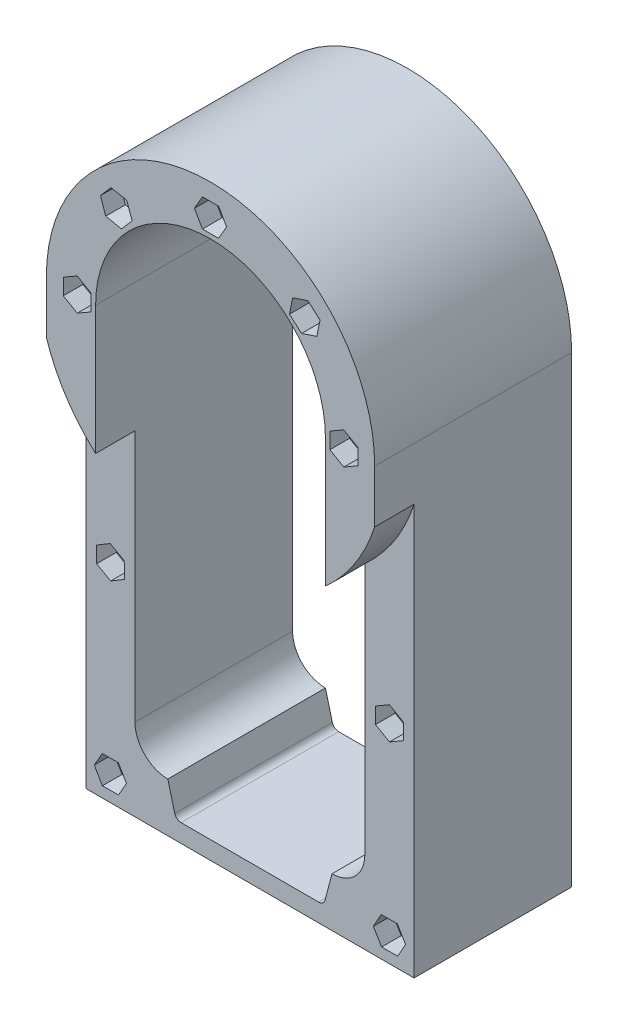
from build123d import *

# Parameters (mm, degrees)
SALIENTE_EXTRUIR1_DEPTH = 60
CROQUIS2_R              = 3
CORTAR_EXTRUIR1_DEPTH   = 60
CORTAR_EXTRUIR2_DEPTH   = 6
CORTAR_EXTRUIR3_DEPTH   = 12
CROQUIS5_R              = 3
CORTAR_EXTRUIR4_DEPTH   = 48
CORTAR_EXTRUIR5_DEPTH   = 6
CORTAR_EXTRUIR6_DEPTH   = 6
CORTAR_EXTRUIR7_DEPTH   = 48


with BuildPart() as part:
    # Croquis1 → Saliente-Extruir1 (new body)
    with BuildSketch(Plane.XY):
        with BuildLine():
            Line((-50, 0), (-50, -141))
            Line((-50, -141), (50, -141))
            Line((50, -141), (50, 0))
            ThreePointArc((50, 0), (0, 50), (-50, 0))
        make_face()
        with BuildLine():
            Line((-35, 0), (-35, -116))
            ThreePointArc((-35, -116), (-32.071067812, -123.071067812), (-25, -126))
            Line((-25, -126), (25, -126))
            ThreePointArc((25, -126), (32.071067812, -123.071067812), (35, -116))
            Line((35, -116), (35, 0))
            ThreePointArc((35, 0), (0, 35), (-35, 0))
        make_face(mode=Mode.SUBTRACT)
    extrude(amount=SALIENTE_EXTRUIR1_DEPTH)

    # Croquis2 → Cortar-Extruir1 (cut)
    with BuildSketch(Plane.XY.offset(60)):
        with Locations((0, 40.605)):
            Circle(CROQUIS2_R)
        with Locations((28.71207085, 28.71207085)):
            Circle(CROQUIS2_R)
        with Locations((40.605, 0)):
            Circle(CROQUIS2_R)
        with Locations((-40.605, 0)):
            Circle(CROQUIS2_R)
        with Locations((-28.71207085, 28.71207085)):
            Circle(CROQUIS2_R)
    extrude(amount=-CORTAR_EXTRUIR1_DEPTH, mode=Mode.SUBTRACT)

    # Croquis3 → Cortar-Extruir2 (cut)
    with BuildSketch(Plane.XY.offset(60)):
        Polygon((4.907477288, 40.605), (2.453738644, 44.855), (-2.453738644, 44.855), (-4.907477288, 40.605), (-2.453738644, 36.355), (2.453738644, 36.355), align=None)
        Polygon((33.365133185, 30.271668311), (29.687950997, 33.521539768), (25.034888662, 31.961942307), (24.059008515, 27.152473389), (27.736190704, 23.902601932), (32.389253039, 25.462199393), align=None)
        Polygon((40.605, -4.907477288), (44.855, -2.453738644), (44.855, 2.453738644), (40.605, 4.907477288), (36.355, 2.453738644), (36.355, -2.453738644), align=None)
        Polygon((-33.528922476, 29.650832668), (-31.933488245, 25.009935885), (-27.11663662, 24.071174067), (-23.895219225, 27.773309032), (-25.490653455, 32.414205815), (-30.30750508, 33.352967633), align=None)
        Polygon((-40.605, 4.907477288), (-44.855, 2.453738644), (-44.855, -2.453738644), (-40.605, -4.907477288), (-36.355, -2.453738644), (-36.355, 2.453738644), align=None)
    extrude(amount=-CORTAR_EXTRUIR2_DEPTH, mode=Mode.SUBTRACT)

    # Croquis4 → Cortar-Extruir3 (cut)
    with BuildSketch(Plane.XY.offset(60)):
        with BuildLine():
            Line((-50, -16.007810594), (-50, -141))
            Line((-50, -141), (50, -141))
            Line((50, -141), (50, -16.007810594))
            ThreePointArc((50, -16.007810594), (0, -52.5), (-50, -16.007810594))
        make_face()
    extrude(amount=-CORTAR_EXTRUIR3_DEPTH, mode=Mode.SUBTRACT)

    # Croquis5 → Cortar-Extruir4 (cut)
    with BuildSketch(Plane.XY.offset(48)):
        with Locations((-42.5, -77.565594803)):
            Circle(CROQUIS5_R)
        with Locations((-42.5, -133.5)):
            Circle(CROQUIS5_R)
        with Locations((42.5, -77.565594803)):
            Circle(CROQUIS5_R)
        with Locations((42.5, -133.5)):
            Circle(CROQUIS5_R)
    extrude(amount=-CORTAR_EXTRUIR4_DEPTH, mode=Mode.SUBTRACT)

    # Croquis6 → Cortar-Extruir5 (cut)
    with BuildSketch(Plane.XY.offset(48)):
        Polygon((-42.421317924, -82.472441292), (-38.21120525, -79.950877371), (-38.289887326, -75.044030882), (-42.578682076, -72.658748314), (-46.78879475, -75.180312235), (-46.710112674, -80.087158724), align=None)
        Polygon((42.5, -82.473072091), (46.75, -80.019333447), (46.75, -75.111856159), (42.5, -72.658117515), (38.25, -75.111856159), (38.25, -80.019333447), align=None)
        Polygon((-40.063566251, -129.240055878), (-44.971002953, -129.260014418), (-47.407436703, -133.519958539), (-44.936433749, -137.759944122), (-40.028997047, -137.739985582), (-37.592563297, -133.480041461), align=None)
        Polygon((44.895973885, -129.217168871), (39.988946385, -129.283610185), (37.5929725, -133.566441313), (40.104026115, -137.782831129), (45.011053615, -137.716389815), (47.4070275, -133.433558687), align=None)
    extrude(amount=-CORTAR_EXTRUIR5_DEPTH, mode=Mode.SUBTRACT)

    # Croquis7 → Cortar-Extruir6 (cut)
    with BuildSketch(Plane(origin=(0, 0, 0), x_dir=(-1, 0, 0), z_dir=(0, 0, -1))):
        Polygon((2.357863822, 44.908929778), (-2.548380612, 44.798934857), (-4.906244434, 40.49500508), (-2.357863822, 36.301070222), (2.548380612, 36.411065143), (4.906244434, 40.71499492), align=None)
        Polygon((-40.614441302, 4.907468206), (-44.859712786, 2.445557696), (-44.850271484, -2.461910511), (-40.595558698, -4.907468206), (-36.350287214, -2.445557696), (-36.359728516, 2.461910511), align=None)
        Polygon((44.882492584, -2.405491744), (44.826963251, 2.50167137), (40.549470667, 4.907163114), (36.327507416, 2.405491744), (36.383036749, -2.50167137), (40.660529333, -4.907163114), align=None)
        Polygon((-42.131373877, -72.671981811), (-46.553680106, -74.79954872), (-46.922306229, -79.693161712), (-42.868626123, -82.459207795), (-38.446319894, -80.331640886), (-38.077693771, -75.438027894), align=None)
        Polygon((42.084370643, -72.675749655), (38.057455203, -75.480617811), (38.47308456, -80.370462959), (42.915629357, -82.455439951), (46.942544797, -79.650571795), (46.52691544, -74.760726647), align=None)
        Polygon((47.407477288, -133.5), (44.953738644, -129.25), (40.046261356, -129.25), (37.592522712, -133.5), (40.046261356, -137.75), (44.953738644, -137.75), align=None)
        Polygon((-44.636850652, -137.917827818), (-39.742474206, -137.559480857), (-37.605623555, -133.14165304), (-40.363149348, -129.082172182), (-45.257525794, -129.440519143), (-47.394376445, -133.85834696), align=None)
    extrude(amount=-CORTAR_EXTRUIR6_DEPTH, mode=Mode.SUBTRACT)

    # Croquis8 → Cortar-Extruir7 (cut)
    with BuildSketch(Plane.XY.offset(48)):
        with BuildLine():
            Line((-22.892371948, -134.008986599), (-25, -126))
            Line((-25, -126), (25, -126))
            Line((25, -126), (22.892371948, -134.008986599))
            ThreePointArc((22.892371948, -134.008986599), (22.17929347, -135.083978093), (20.958222873, -135.5))
            Line((20.958222873, -135.5), (-20.958222873, -135.5))
            ThreePointArc((-20.958222873, -135.5), (-22.17929347, -135.083978093), (-22.892371948, -134.008986599))
        make_face()
    extrude(amount=-CORTAR_EXTRUIR7_DEPTH, mode=Mode.SUBTRACT)


solid = part.part
